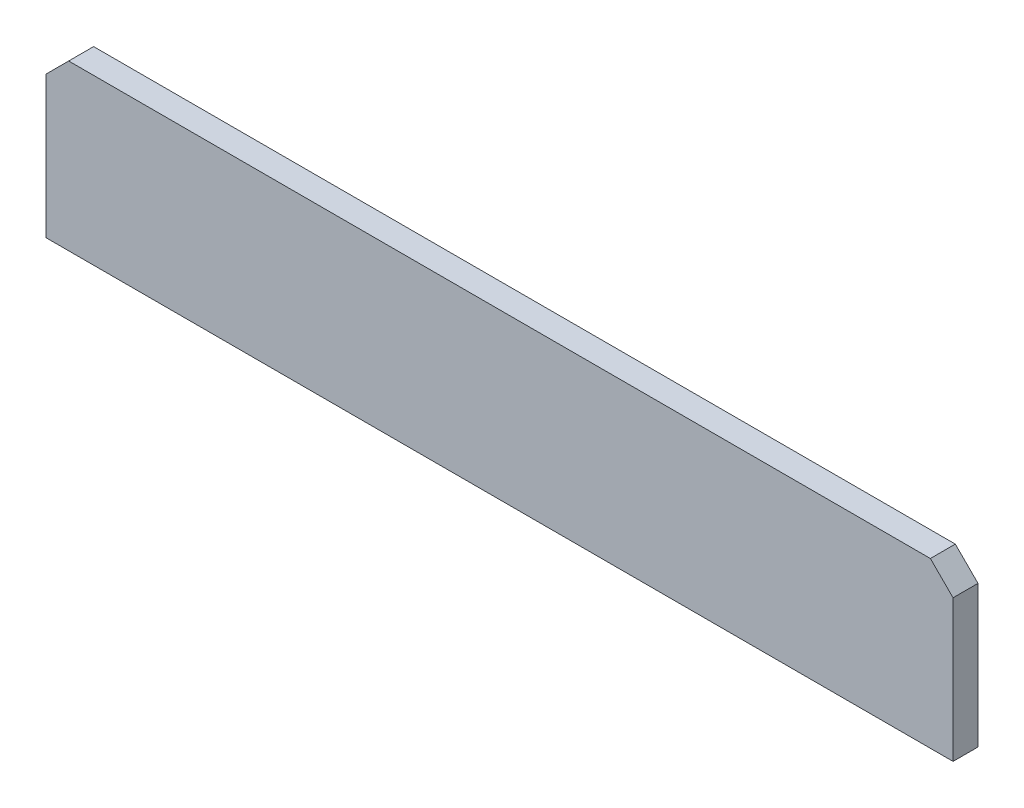
from build123d import *

# Parameters (mm, degrees)
BOSS_EXTRUDE1_DEPTH = 22


with BuildPart() as part:
    # Sketch1 → Boss-Extrude1 (new body)
    with BuildSketch(Plane.XY):
        Polygon((400, -20), (380, 0), (-380, 0), (-400, -20), (-400, -145), (400, -145), align=None)
    extrude(amount=BOSS_EXTRUDE1_DEPTH)


solid = part.part
